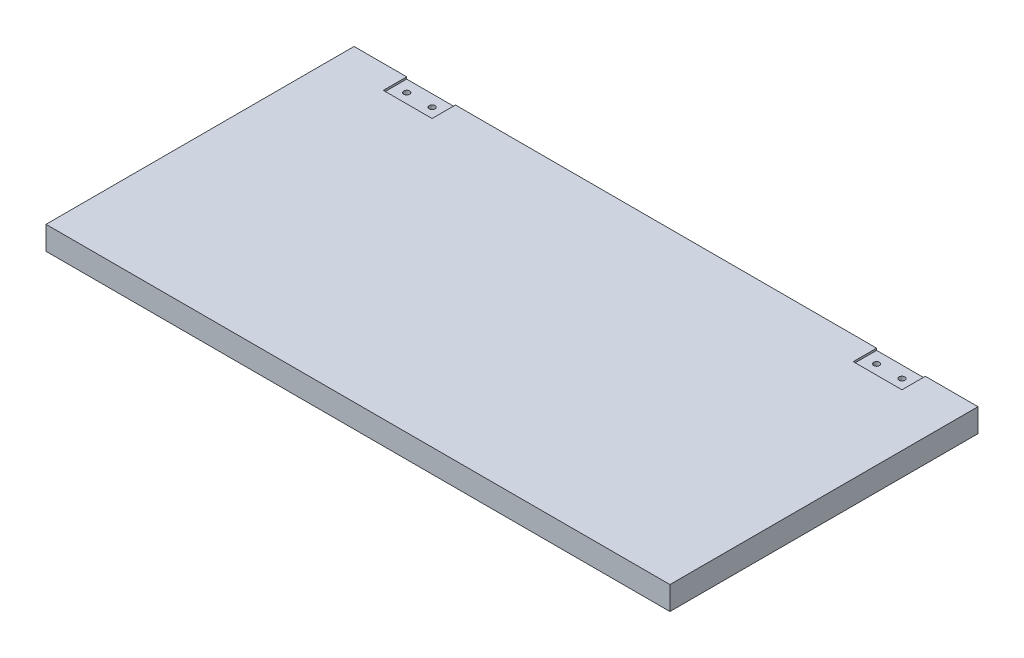
from build123d import *

# Parameters (mm, degrees)
SKETCH1_W           = 320
SKETCH1_H           = 158
BOSS_EXTRUDE1_DEPTH = 12
CUT_EXTRUDE1_START  = 12
SKETCH2_W           = 25
SKETCH2_H           = 12
CUT_EXTRUDE1_DEPTH  = 1
CUT_EXTRUDE5_START  = 3
SKETCH3_R           = 1.5
CUT_EXTRUDE5_DEPTH  = 9


with BuildPart() as part:
    # Sketch1 → Boss-Extrude1 (new body)
    with BuildSketch(Plane(origin=(0, 0, 0), x_dir=(1, 0, 0), z_dir=(0, 1, 0))):
        with Locations((160, 79)):
            Rectangle(SKETCH1_W, SKETCH1_H)
    extrude(amount=BOSS_EXTRUDE1_DEPTH)

    # Sketch2 → Cut-Extrude1 (cut)
    with BuildSketch(Plane(origin=(0, 0, 0), x_dir=(1, 0, 0), z_dir=(0, 1, 0)).offset(CUT_EXTRUDE1_START)):
        with Locations((39.5, 152)):
            Rectangle(SKETCH2_W, SKETCH2_H)
        with Locations((280.5, 152)):
            Rectangle(SKETCH2_W, SKETCH2_H)
    extrude(amount=-CUT_EXTRUDE1_DEPTH, mode=Mode.SUBTRACT)

    # Sketch3 → Cut-Extrude5 (cut)
    with BuildSketch(Plane(origin=(0, 0, 0), x_dir=(1, 0, 0), z_dir=(0, 1, 0)).offset(CUT_EXTRUDE5_START)):
        with Locations((33, 152)):
            Circle(SKETCH3_R)
        with Locations((46, 152)):
            Circle(SKETCH3_R)
        with Locations((274, 152)):
            Circle(SKETCH3_R)
        with Locations((287, 152)):
            Circle(SKETCH3_R)
    extrude(amount=CUT_EXTRUDE5_DEPTH, mode=Mode.SUBTRACT)


solid = part.part
